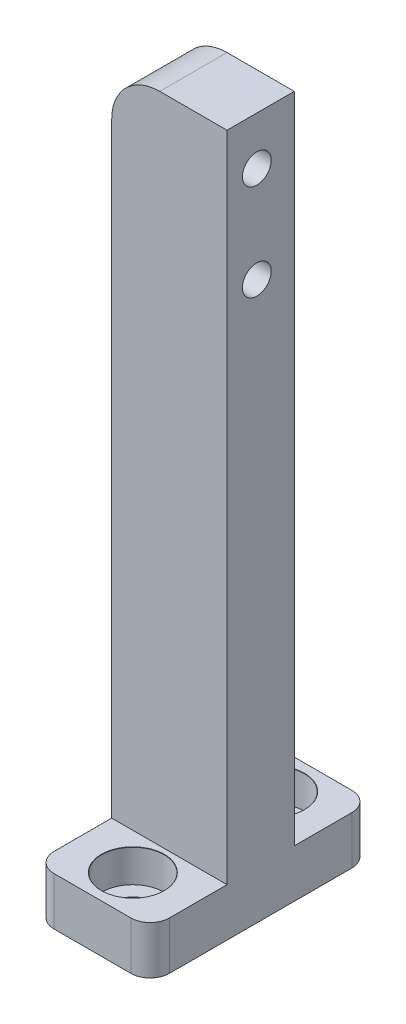
from build123d import *

# Parameters (mm, degrees)
SKETCH1_W           = 12
SKETCH1_H           = 7
BOSS_EXTRUDE1_DEPTH = 36.5
SKETCH3_W           = 12
SKETCH3_H           = 5
BOSS_EXTRUDE2_DEPTH = 11.5
FILLET1_R           = 2
FILLET2_R           = 5
CUT_EXTRUDE1_REACH  = 14
SKETCH7_R           = 1.5


with BuildPart() as part:
    # Sketch1 → Boss-Extrude1 (new body, symmetric)
    with BuildSketch(Plane(origin=(0, 0, 0), x_dir=(1, 0, 0), z_dir=(0, 1, 0))):
        Rectangle(SKETCH1_W, SKETCH1_H)
    extrude(amount=BOSS_EXTRUDE1_DEPTH, both=True)

    # Sketch3 → Boss-Extrude2 (add, symmetric)
    with BuildSketch(Plane.XY):
        with Locations((0, -34)):
            Rectangle(SKETCH3_W, SKETCH3_H)
    extrude(amount=BOSS_EXTRUDE2_DEPTH, both=True)

    # Fillet1
    fillet1_edges = [part.edges().sort_by_distance(p)[0] for p in [
        (-6, -34, -11.5),
        (6, -34, -11.5),
        (-6, -34, 11.5),
        (6, -34, 11.5),
    ]]
    fillet(fillet1_edges, radius=FILLET1_R)

    # Sketch6 → CBORE for M3 Hex Socket Head Cap Screw1 (revolve, cut)
    with BuildSketch(Plane(origin=(0, -31.5, -7.3), x_dir=(0, 0, 1), z_dir=(1, 0, 0))):
        Polygon((0, 0), (0, 5), (1.7, 5), (1.7, 3.4), (3.25, 3.4), (3.25, 0.025), (3.275, 0), align=None)
    cbore_for_m3_hex_socket_head_cap_screw1 = revolve(axis=Axis((0, -25.15, -7.3), (0, -1, 0)), mode=Mode.SUBTRACT)

    # Mirror1: CBORE for M3 Hex Socket Head Cap Screw1 across plane
    add(cbore_for_m3_hex_socket_head_cap_screw1.mirror(Plane.XY), mode=Mode.SUBTRACT)

    # Fillet2
    fillet2_edges = [part.edges().sort_by_distance(p)[0] for p in [
        (-6, 36.5, 0),
    ]]
    fillet(fillet2_edges, radius=FILLET2_R)

    # Sketch7 → Cut-Extrude1 (cut, up to next)
    with BuildSketch(Plane(origin=(6, 0, 0), x_dir=(0, 0, -1), z_dir=(1, 0, 0)), mode=Mode.PRIVATE) as cut_extrude1_sk1:
        with Locations((-0.4, 31.5)):
            Circle(SKETCH7_R)
    cut_extrude1_tool1 = extrude(cut_extrude1_sk1.sketch, amount=-CUT_EXTRUDE1_REACH, mode=Mode.PRIVATE) & part.part
    add(cut_extrude1_tool1.solids().sort_by_distance((6, 31.5, 0.4))[0], mode=Mode.SUBTRACT)
    # Sketch7 → Cut-Extrude1 (cut, up to next)
    with BuildSketch(Plane(origin=(6, 0, 0), x_dir=(0, 0, -1), z_dir=(1, 0, 0)), mode=Mode.PRIVATE) as cut_extrude1_sk2:
        with Locations((-0.4, 21.5)):
            Circle(SKETCH7_R)
    cut_extrude1_tool2 = extrude(cut_extrude1_sk2.sketch, amount=-CUT_EXTRUDE1_REACH, mode=Mode.PRIVATE) & part.part
    add(cut_extrude1_tool2.solids().sort_by_distance((6, 21.5, 0.4))[0], mode=Mode.SUBTRACT)


solid = part.part
